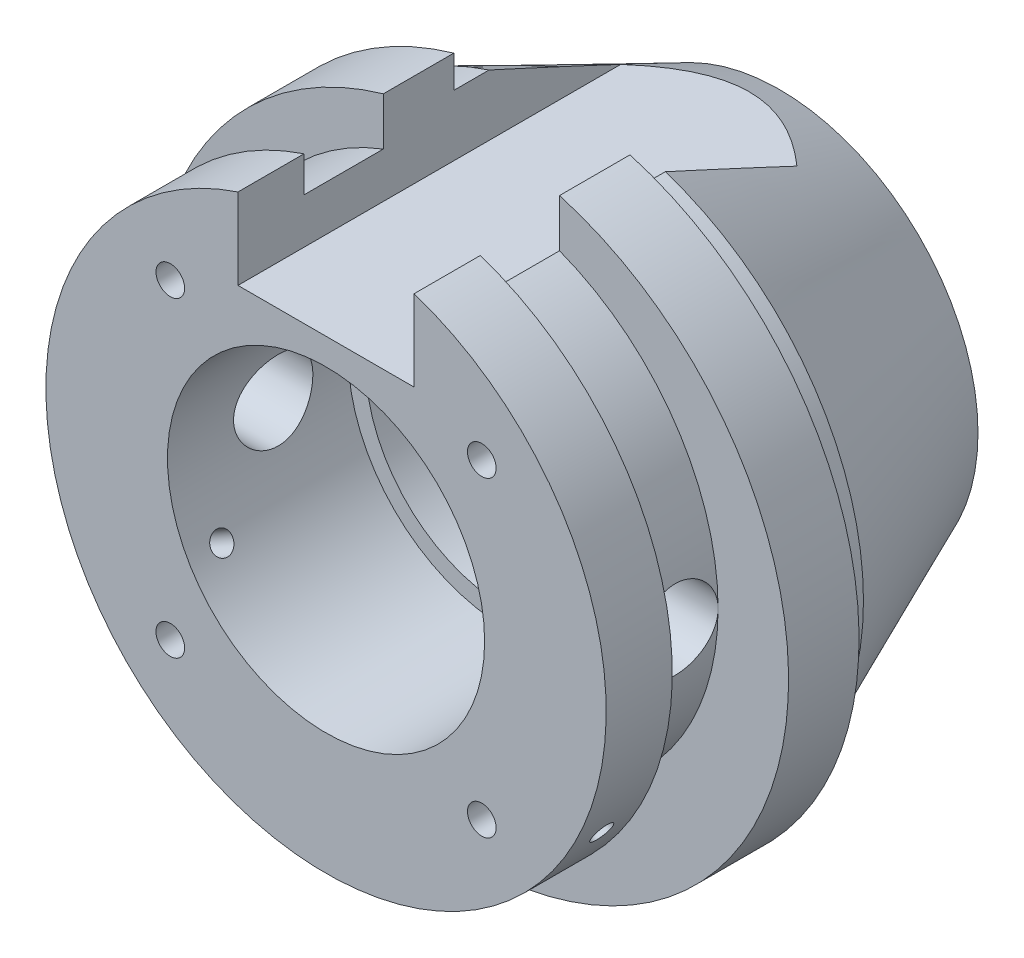
from build123d import *

# Parameters (mm, degrees)
ESQUISSE1_R                  = 36
BASE_EXTRUSION_DEPTH         = 8
ESQUISSE2_R                  = 32.5
BOSS_EXTRU_1_DEPTH           = 4
ESQUISSE4_R                  = 28
BOSS_EXTRU_2_DEPTH           = 9
ESQUISSE5_R                  = 31.8
BOSS_EXTRU_3_DEPTH           = 7.5
ESQUISSE6_R                  = 18
ENL_V_MAT_EXTRU_1_DEPTH      = 52.5
ESQUISSE10_W                 = 20
ESQUISSE10_H                 = 14.61003861
ENL_V_MAT_EXTRU_5_DEPTH      = 52.5
R_P_TITION_CIRCULAIRE1_COUNT = 4
ESQUISSE13_R                 = 4.5
ENL_V_MAT_EXTRU_6_DEPTH      = 37
ENL_V_MAT_EXTRU_6_DEPTH_BACK = 37
ENL_V_START                  = -31.8
ESQUISSE14_R                 = 1.23
ENL_V_MAT_EXTRU_7_DEPTH      = 13.842074
R_P_TITION_CIRCULAIRE2_COUNT = 2
R_P_TITION_CIRCULAIRE2_ANGLE = 120


with BuildPart() as part:
    # Esquisse1 → Base-Extrusion (new body)
    with BuildSketch(Plane.XY):
        Circle(ESQUISSE1_R)
    extrude(amount=BASE_EXTRUSION_DEPTH)

    # Esquisse2 → Boss.-Extru.1 (add)
    with BuildSketch(Plane(origin=(0, 0, 0), x_dir=(-1, 0, 0), z_dir=(0, 0, -1))):
        Circle(ESQUISSE2_R)
    extrude(amount=BOSS_EXTRU_1_DEPTH)

    # Esquisse3 → Boss.-Révol.1 (revolve)
    with BuildSketch(Plane(origin=(0, 0, 0), x_dir=(0, 0, -1), z_dir=(1, 0, 0))):
        Polygon((4, 32.5), (27, 22.499315376), (27, 0), (4, 0), align=None)
    revolve(axis=Axis((0, 0, 0), (0, 0, -1)))

    # Esquisse4 → Boss.-Extru.2 (add)
    with BuildSketch(Plane.XY.offset(8)):
        with Locations((0, 3)):
            Circle(ESQUISSE4_R)
    extrude(amount=BOSS_EXTRU_2_DEPTH)

    # Esquisse5 → Boss.-Extru.3 (add)
    with BuildSketch(Plane.XY.offset(17)):
        with Locations((0, 3)):
            Circle(ESQUISSE5_R)
    extrude(amount=BOSS_EXTRU_3_DEPTH)

    # Esquisse6 → Enlèv. mat.-Extru.1 (cut, through all)
    with BuildSketch(Plane.XY.offset(24.5)):
        with Locations((0, 3)):
            Circle(ESQUISSE6_R)
    extrude(amount=-ENL_V_MAT_EXTRU_1_DEPTH, mode=Mode.SUBTRACT)

    # Esquisse10 → Enlèv. mat.-Extru.5 (cut, through all)
    with BuildSketch(Plane.XY.offset(24.5)):
        with Locations((0, 31.305019305)):
            Rectangle(ESQUISSE10_W, ESQUISSE10_H)
    extrude(amount=-ENL_V_MAT_EXTRU_5_DEPTH, mode=Mode.SUBTRACT)

    # Esquisse11 → Perçage1 (revolve, cut)
    with BuildSketch(Plane(origin=(-17.67766953, 20.67766953, 24.5), x_dir=(0, -1, 0), z_dir=(1, 0, 0))):
        Polygon((0, 0), (0, 12.976398506), (1.625, 12), (1.625, 0), align=None)
    per_age1 = revolve(axis=Axis((-17.67766953, 20.67766953, 28.744199587), (0, 0, -1)), mode=Mode.SUBTRACT)

    # Répétition circulaire1: Perçage1 ×4 about axis
    r_p_tition_circulaire1_axis = Axis((0, 3, 0), (0, 0, 1))
    for i in range(1, R_P_TITION_CIRCULAIRE1_COUNT):
        add(per_age1.rotate(r_p_tition_circulaire1_axis, i * 360 / R_P_TITION_CIRCULAIRE1_COUNT), mode=Mode.SUBTRACT)

    # Esquisse13 → Enlèv. mat.-Extru.6 (cut, two sides)
    with BuildSketch(Plane(origin=(0, 0, 0), x_dir=(0, 0, -1), z_dir=(1, 0, 0))) as enl_v_mat_extru_6_sk:
        with Locations((-12.5, 3)):
            Circle(ESQUISSE13_R)
    extrude(amount=ENL_V_MAT_EXTRU_6_DEPTH, mode=Mode.SUBTRACT)
    extrude(enl_v_mat_extru_6_sk.sketch, amount=-ENL_V_MAT_EXTRU_6_DEPTH_BACK, mode=Mode.SUBTRACT)

    # Esquisse14 → Enlèv. mat.-Extru.7 (cut)
    with BuildSketch(Plane(origin=(-1.299038106, 0.75, 0), x_dir=(0, 0, 1), z_dir=(-0.866025404, 0.5, 0)).offset(ENL_V_START)):
        with Locations((20.75, 2.598076211)):
            Circle(ESQUISSE14_R)
    enl_v_mat_extru_7 = extrude(amount=ENL_V_MAT_EXTRU_7_DEPTH, mode=Mode.SUBTRACT)

    # Répétition circulaire2: Enlèv. mat.-Extru.7 ×2 about axis
    r_p_tition_circulaire2_axis = Axis((0, 3, 0), (0, 0, -1))
    for i in range(1, R_P_TITION_CIRCULAIRE2_COUNT):
        add(enl_v_mat_extru_7.rotate(r_p_tition_circulaire2_axis, i * R_P_TITION_CIRCULAIRE2_ANGLE / (R_P_TITION_CIRCULAIRE2_COUNT - 1)), mode=Mode.SUBTRACT)

    # Esquisse16 → Révolution1 (revolve)
    with BuildSketch(Plane(origin=(0, 0, 0), x_dir=(0, 0, -1), z_dir=(1, 0, 0))):
        Polygon((27, -15), (27, -13), (17, -13), (17, -11), (4, -11), (4, -13), (-4, -13), (-4, -15), align=None)
    revolve(axis=Axis((0, 3, -27), (0, 0, 1)))


solid = part.part
